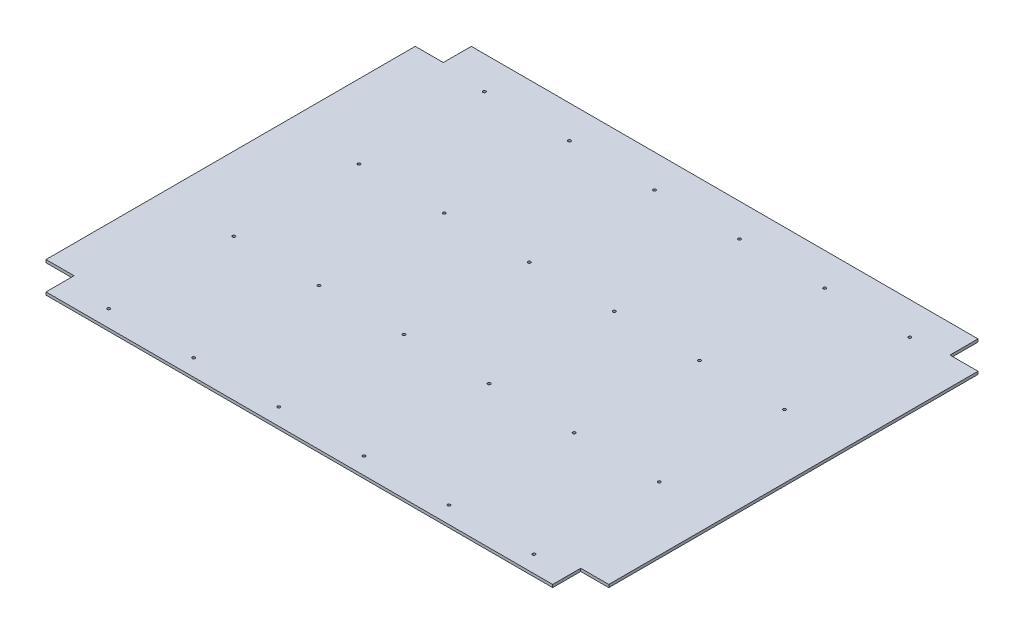
from build123d import *

# Parameters (mm, degrees)
SKETCH1_W           = 542
SKETCH1_H           = 455
SKETCH1_R           = 1.5
BOSS_EXTRUDE1_DEPTH = 3
SKETCH2_W           = 30
SKETCH2_H           = 395
BOSS_EXTRUDE2_DEPTH = 3


with BuildPart() as part:
    # Sketch1 → Boss-Extrude1 (new body)
    with BuildSketch(Plane(origin=(0, 0, 0), x_dir=(1, 0, 0), z_dir=(0, 1, 0))):
        with Locations((271, 227.5)):
            Rectangle(SKETCH1_W, SKETCH1_H)
        with Locations((49, 18)):
            Circle(SKETCH1_R, mode=Mode.SUBTRACT)
        with Locations((140, 18)):
            Circle(SKETCH1_R, mode=Mode.SUBTRACT)
        with Locations((231, 18)):
            Circle(SKETCH1_R, mode=Mode.SUBTRACT)
        with Locations((413, 18)):
            Circle(SKETCH1_R, mode=Mode.SUBTRACT)
        with Locations((504, 18)):
            Circle(SKETCH1_R, mode=Mode.SUBTRACT)
        with Locations((322, 18)):
            Circle(SKETCH1_R, mode=Mode.SUBTRACT)
        with Locations((49, 152)):
            Circle(SKETCH1_R, mode=Mode.SUBTRACT)
        with Locations((140, 152)):
            Circle(SKETCH1_R, mode=Mode.SUBTRACT)
        with Locations((231, 152)):
            Circle(SKETCH1_R, mode=Mode.SUBTRACT)
        with Locations((322, 152)):
            Circle(SKETCH1_R, mode=Mode.SUBTRACT)
        with Locations((413, 152)):
            Circle(SKETCH1_R, mode=Mode.SUBTRACT)
        with Locations((504, 152)):
            Circle(SKETCH1_R, mode=Mode.SUBTRACT)
        with Locations((49, 286)):
            Circle(SKETCH1_R, mode=Mode.SUBTRACT)
        with Locations((140, 286)):
            Circle(SKETCH1_R, mode=Mode.SUBTRACT)
        with Locations((231, 286)):
            Circle(SKETCH1_R, mode=Mode.SUBTRACT)
        with Locations((322, 286)):
            Circle(SKETCH1_R, mode=Mode.SUBTRACT)
        with Locations((413, 286)):
            Circle(SKETCH1_R, mode=Mode.SUBTRACT)
        with Locations((504, 286)):
            Circle(SKETCH1_R, mode=Mode.SUBTRACT)
        with Locations((49, 420)):
            Circle(SKETCH1_R, mode=Mode.SUBTRACT)
        with Locations((140, 420)):
            Circle(SKETCH1_R, mode=Mode.SUBTRACT)
        with Locations((231, 420)):
            Circle(SKETCH1_R, mode=Mode.SUBTRACT)
        with Locations((322, 420)):
            Circle(SKETCH1_R, mode=Mode.SUBTRACT)
        with Locations((413, 420)):
            Circle(SKETCH1_R, mode=Mode.SUBTRACT)
        with Locations((504, 420)):
            Circle(SKETCH1_R, mode=Mode.SUBTRACT)
    extrude(amount=BOSS_EXTRUDE1_DEPTH)

    # Sketch2 → Boss-Extrude2 (add)
    with BuildSketch(Plane(origin=(0, 0, 0), x_dir=(1, 0, 0), z_dir=(0, 1, 0))):
        with Locations((-15, 227.5)):
            Rectangle(SKETCH2_W, SKETCH2_H)
        with Locations((557, 227.5)):
            Rectangle(SKETCH2_W, SKETCH2_H)
    extrude(amount=BOSS_EXTRUDE2_DEPTH)


solid = part.part
